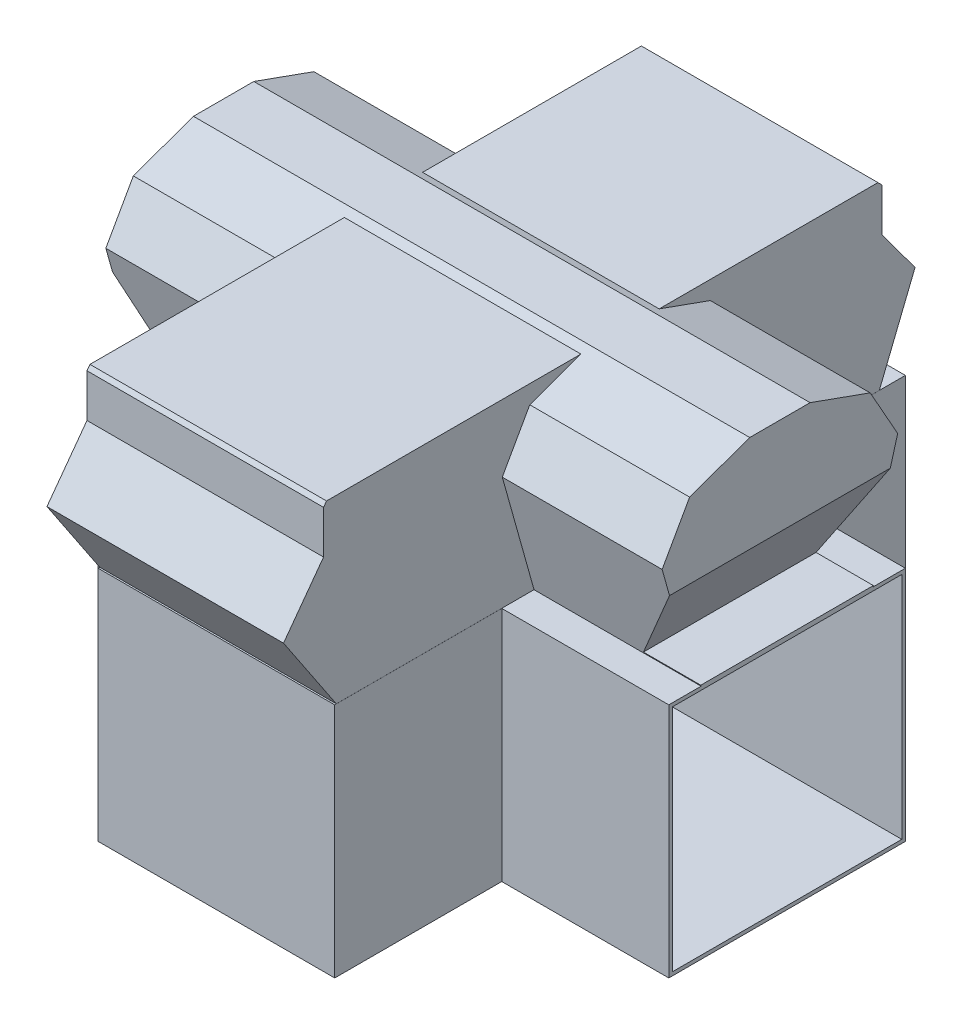
from build123d import *

# Parameters (mm, degrees)
BOSS_EXTRUDE1_DEPTH             = 419.1
SKETCH2_W                       = 406.4
SKETCH2_H                       = 406.4
CUT_EXTRUDE1_DEPTH              = 406.4
BOSS_EXTRUDE2_START             = -505.46
BOSS_EXTRUDE2_DEPTH             = 1010.92
CUT_EXTRUDE2_DEPTH              = 453.007941176
CUT_EXTRUDE2_DEPTH_BACK         = 559.912058824
BOSS_EXTRUDE3_REACH             = 409.409
BOSS_EXTRUDE3_DIRECTION_2_REACH = 605.511


with BuildPart() as part:
    # Sketch1 → Boss-Extrude1 (new body)
    with BuildSketch(Plane(origin=(0, 0, 0), x_dir=(1, 0, 0), z_dir=(0, 1, 0))):
        Polygon((-111.498529412, 263.002058824), (-111.498529412, 558.912058824), (307.601470588, 558.912058824), (307.601470588, 263.002058824), (603.511470588, 263.002058824), (603.511470588, -156.097941176), (307.601470588, -156.097941176), (307.601470588, -452.007941176), (-111.498529412, -452.007941176), (-111.498529412, -156.097941176), (-407.408529412, -156.097941176), (-407.408529412, 263.002058824), align=None)
    extrude(amount=BOSS_EXTRUDE1_DEPTH)

    # Sketch2 → Cut-Extrude1 (cut)
    with BuildSketch(Plane.ZY.offset(407.408529412)):
        with Locations((-53.452058824, 209.55)):
            Rectangle(SKETCH2_W, SKETCH2_H)
    cut_extrude1 = extrude(amount=-CUT_EXTRUDE1_DEPTH, mode=Mode.SUBTRACT)

    # Mirror1: Cut-Extrude1 across plane
    add(cut_extrude1.mirror(Plane.ZY.offset(-98.051470588)), mode=Mode.SUBTRACT)

    # Sketch3 → Boss-Extrude2 (add)
    with BuildSketch(Plane.ZY.offset(-98.051470588).offset(BOSS_EXTRUDE2_START)):
        Polygon((-205.790064307, 419.1), (98.88594666, 419.1), (155.185867753, 620.042461281), (106.481982696, 706.660847592), (0, 744.864396526), (-106.904117647, 744.864396526), (-213.386100343, 706.660847592), (-262.0899854, 620.042461281), align=None)
    extrude(amount=BOSS_EXTRUDE2_DEPTH)

    # Sketch4 → Cut-Extrude2 (cut, two sides)
    with BuildSketch(Plane.XY) as cut_extrude2_sk:
        Polygon((-305.808529412, 425.454129149), (-394.708529412, 577.854129149), (-394.708529412, 796.580225866), (590.811470588, 796.580225866), (590.811470588, 573.314003685), (501.911470588, 420.914003685), (647.189097077, 420.914003685), (647.189097077, 885.635632277), (-516.891145843, 876.882773083), (-501.7416469, 425.454129149), align=None)
    extrude(amount=CUT_EXTRUDE2_DEPTH, mode=Mode.SUBTRACT)
    extrude(cut_extrude2_sk.sketch, amount=-CUT_EXTRUDE2_DEPTH_BACK, mode=Mode.SUBTRACT)

    # Boss-Extrude3: up to this face of the body (flat: up to its plane)
    boss_extrude3_end = Plane(part.part.faces().sort_by_distance((-111.498529412, 209.55, 304.052941176))[0])
    # Sketch5 → Boss-Extrude3 (add, up to the picked face)
    with BuildSketch(Plane(origin=(0, 0, 0), x_dir=(0, 0, -1), z_dir=(1, 0, 0)), mode=Mode.PRIVATE) as boss_extrude3_sk1:
        Polygon((-449.181000693, 419.206207419), (-542.705165158, 559.069271968), (-471.821113531, 655.706983405), (-471.821113531, 732.000172587), (-466.55643227, 739.177622759), (510.328311202, 739.177622759), (517.505761373, 732.000172587), (517.505761373, 655.706983405), (576.040352368, 576.087761543), (512.785450653, 419.206207419), align=None)
    boss_extrude3_tool1 = split(extrude(boss_extrude3_sk1.sketch, amount=-BOSS_EXTRUDE3_REACH, mode=Mode.PRIVATE), bisect_by=boss_extrude3_end, keep=Keep.BOTH, mode=Mode.PRIVATE)
    add(boss_extrude3_tool1.solids().sort_by_distance((0, 578.35257, -22.327279))[0])

    # Boss-Extrude3 direction 2: up to this face of the body (flat: up to its plane)
    boss_extrude3_direction_2_end = Plane(part.part.faces().sort_by_distance((307.601470588, 209.55, 304.052941176))[0])
    # Sketch5 → Boss-Extrude3 direction 2 (add, up to the picked face)
    with BuildSketch(Plane(origin=(0, 0, 0), x_dir=(0, 0, -1), z_dir=(1, 0, 0)), mode=Mode.PRIVATE) as boss_extrude3_direction_2_sk1:
        Polygon((-449.181000693, 419.206207419), (-542.705165158, 559.069271968), (-471.821113531, 655.706983405), (-471.821113531, 732.000172587), (-466.55643227, 739.177622759), (510.328311202, 739.177622759), (517.505761373, 732.000172587), (517.505761373, 655.706983405), (576.040352368, 576.087761543), (512.785450653, 419.206207419), align=None)
    boss_extrude3_direction_2_tool1 = split(extrude(boss_extrude3_direction_2_sk1.sketch, amount=BOSS_EXTRUDE3_DIRECTION_2_REACH, mode=Mode.PRIVATE), bisect_by=boss_extrude3_direction_2_end, keep=Keep.BOTH, mode=Mode.PRIVATE)
    add(boss_extrude3_direction_2_tool1.solids().sort_by_distance((0, 578.35257, -22.327279))[0])


solid = part.part
